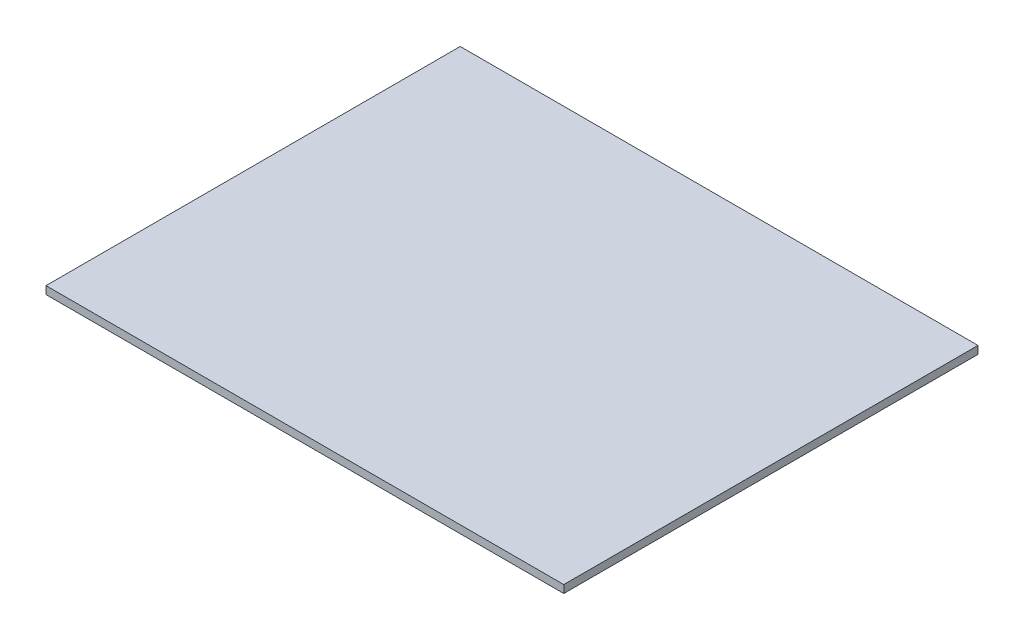
from build123d import *

# Parameters (mm, degrees)
SKETCH1_W           = 317.5
SKETCH1_H           = 254
BOSS_EXTRUDE1_DEPTH = 4.7625


with BuildPart() as part:
    # Sketch1 → Boss-Extrude1 (new body)
    with BuildSketch(Plane(origin=(0, 0, 0), x_dir=(1, 0, 0), z_dir=(0, 1, 0))):
        with Locations((158.75, -127)):
            Rectangle(SKETCH1_W, SKETCH1_H)
    extrude(amount=BOSS_EXTRUDE1_DEPTH)


solid = part.part
